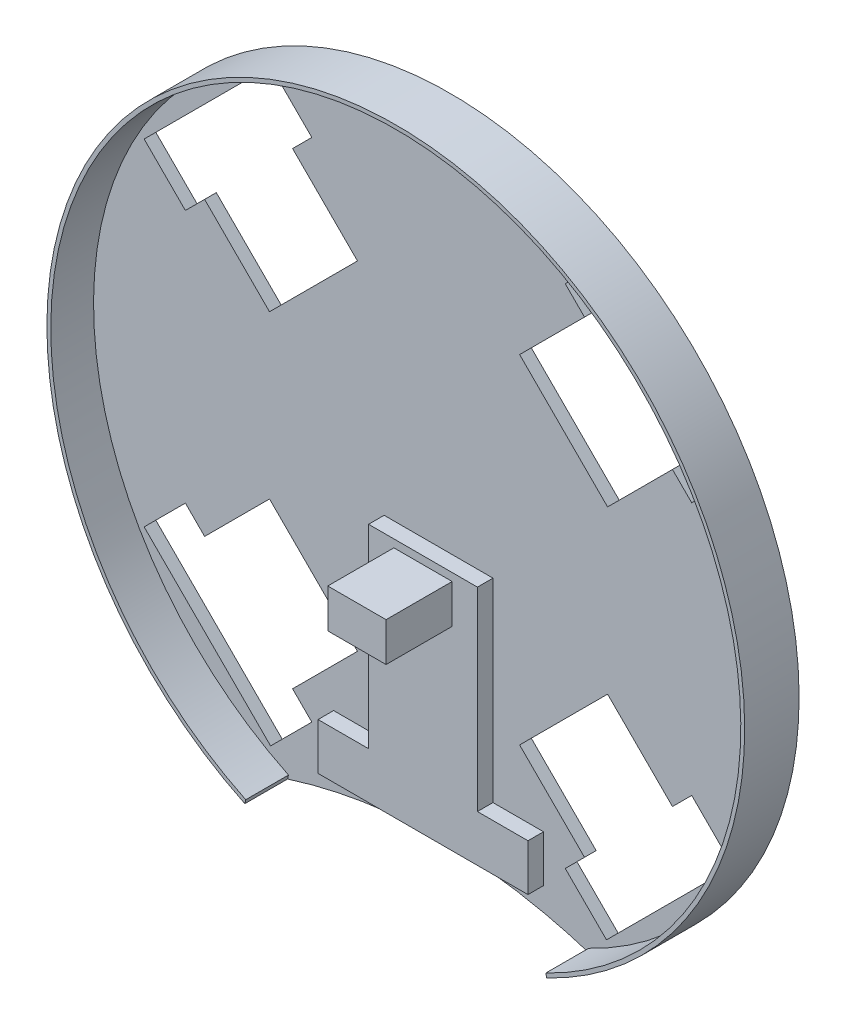
from build123d import *

# Parameters (mm, degrees)
BOSS_EXTRUDE1_DEPTH = 3
BOSS_EXTRUDE2_DEPTH = 11
SKETCH3_W           = 28
SKETCH3_H           = 50
SKETCH3_W_2         = 54
SKETCH3_H_2         = 12
BOSS_EXTRUDE3_DEPTH = 4
SKETCH4_W           = 15
SKETCH4_H           = 10
BOSS_EXTRUDE4_DEPTH = 17


with BuildPart() as part:
    # Model → Boss-Extrude1 (new body)
    with BuildSketch(Plane.XY):
        with BuildLine():
            ThreePointArc((38.829215393, -80.915724874), (0, 89.75), (-38.829215393, -80.915724874))
            add(Edge.make_bspline(
                [(38.829215393, -80.915724874), (12.943071798, -72.694758375), (-12.943071798, -72.694758375), (-38.829215393, -80.915724874)],
                knots=[0, 0, 0, 0, 1, 1, 1, 1], degree=3))
        make_face()
        Polygon((-20.854851634, -43.482268632), (-37.546710486, -60.174127484), (-32.596963018, -65.123874952), (-43.203564736, -75.73047667), (-75.73047667, -43.203564736), (-65.123874952, -32.596963018), (-60.174127484, -37.546710486), (-43.482268632, -20.854851634), align=None, mode=Mode.SUBTRACT)
        Polygon((43.482268632, -20.854851634), (60.174127484, -37.546710486), (65.123874952, -32.596963018), (75.73047667, -43.203564736), (43.203564736, -75.73047667), (32.596963018, -65.123874952), (37.546710486, -60.174127484), (20.854851634, -43.482268632), align=None, mode=Mode.SUBTRACT)
        Polygon((20.854851634, 43.482268632), (37.546710486, 60.174127484), (32.596963018, 65.123874952), (43.203564736, 75.73047667), (75.73047667, 43.203564736), (65.123874952, 32.596963018), (60.174127484, 37.546710486), (43.482268632, 20.854851634), align=None, mode=Mode.SUBTRACT)
        Polygon((-43.482268632, 20.854851634), (-60.174127484, 37.546710486), (-65.123874952, 32.596963018), (-75.73047667, 43.203564736), (-43.203564736, 75.73047667), (-32.596963018, 65.123874952), (-37.546710486, 60.174127484), (-20.854851634, 43.482268632), align=None, mode=Mode.SUBTRACT)
    extrude(amount=BOSS_EXTRUDE1_DEPTH)

    # Sketch2 → Boss-Extrude2 (add)
    with BuildSketch(Plane.XY.offset(3)):
        with BuildLine():
            Line((-38.829215393, -80.915724874), (-38.601028715, -79.915724874))
            ThreePointArc((-38.601028715, -79.915724874), (0, 88.75), (38.601028715, -79.915724874))
            Line((38.601028715, -79.915724874), (38.829215393, -80.915724874))
            ThreePointArc((38.829215393, -80.915724874), (0, 89.75), (-38.829215393, -80.915724874))
        make_face()
    extrude(amount=BOSS_EXTRUDE2_DEPTH)

    # Sketch3 → Boss-Extrude3 (add)
    with BuildSketch(Plane.XY.offset(3)):
        with Locations((0, -34.75)):
            Rectangle(SKETCH3_W, SKETCH3_H)
        with Locations((0, -65.75)):
            Rectangle(SKETCH3_W_2, SKETCH3_H_2)
    extrude(amount=BOSS_EXTRUDE3_DEPTH)

    # Sketch4 → Boss-Extrude4 (add)
    with BuildSketch(Plane.XY.offset(7)):
        with Locations((0, -16.75)):
            Rectangle(SKETCH4_W, SKETCH4_H)
    extrude(amount=BOSS_EXTRUDE4_DEPTH)


solid = part.part
